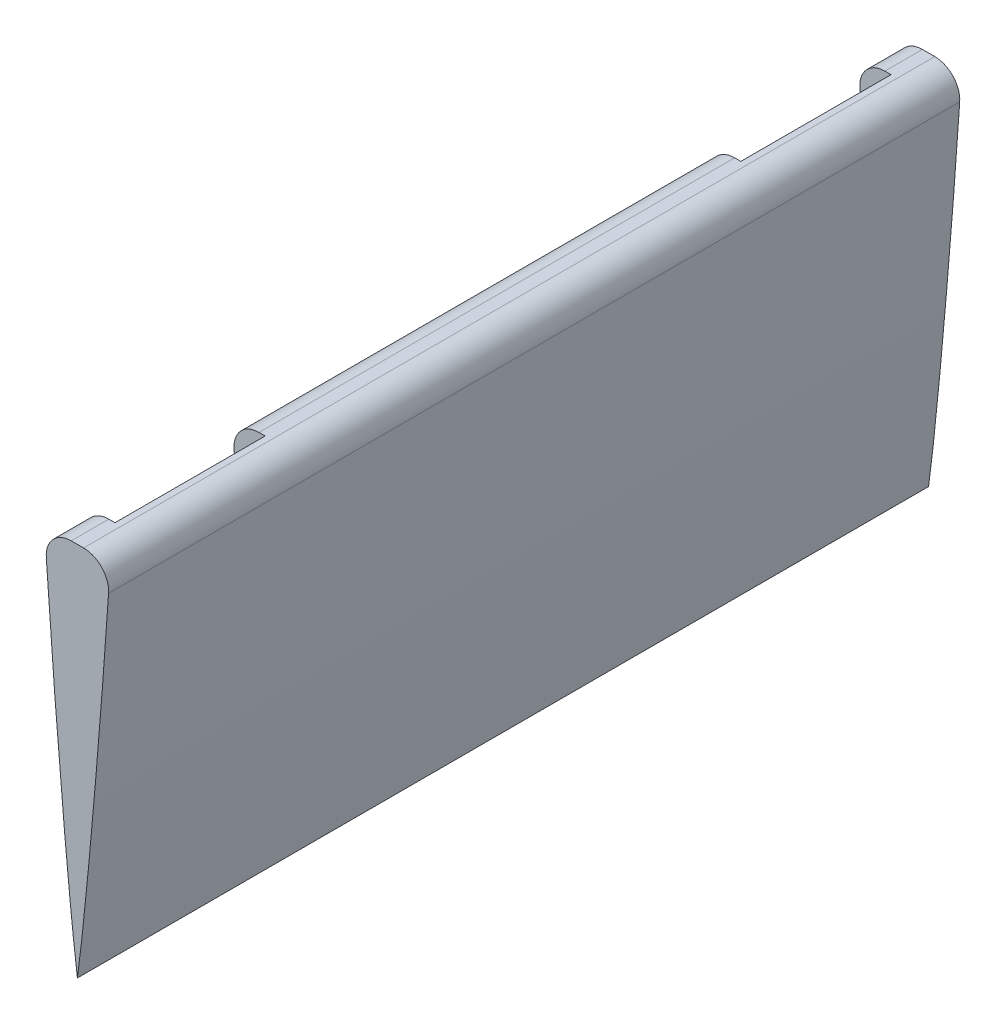
from build123d import *

# Parameters (mm, degrees)
BOSS_EXTRUDE1_DEPTH = 34
SKETCH4_W           = 12
SKETCH4_H           = 12
CUT_EXTRUDE1_DEPTH  = 3.493295554


with BuildPart() as part:
    # Sketch2 → Boss-Extrude1 (new body, symmetric)
    with BuildSketch(Plane.XY.offset(35)):
        with BuildLine():
            Line((-0.493295454, -665), (0.493295611, -665))
            ThreePointArc((0.493295611, -665), (1.954790004, -665.634703644), (2.488668579, -667.135965861))
            add(Edge.make_bspline(
                [(0, -695), (0.015522073, -694.884094445), (0.077278927, -694.422947112), (0.206148599, -693.392547034), (0.403716276, -691.694585868), (0.648953841, -689.357636132), (0.936738043, -686.422103162), (1.254326755, -682.93824868), (1.595587122, -678.965683583), (1.950533146, -674.572635912), (2.249009374, -670.582285025), (2.425394007, -668.064554633), (2.488668579, -667.135965861)],
                knots=[0.816447502, 0.816447502, 0.816447502, 0.816447502, 0.818585491, 0.824953805, 0.835432492, 0.849837851, 0.867913595, 0.889359146, 0.913796005, 0.94081031, 0.969937518, 0.986954026, 0.986954026, 0.986954026, 0.986954026], degree=3))
            Line((0, -695), (-0.0463125, -694.65225))
            add(Edge.make_bspline(
                [(-2.488668416, -667.135965964), (-2.425393799, -668.064554688), (-2.249009192, -670.582285042), (-1.950535166, -674.572636178), (-1.595580455, -678.965682707), (-1.254347923, -682.938251461), (-0.936673997, -686.422094747), (-0.649135543, -689.357660004), (-0.403246318, -691.694524123), (-0.207189019, -693.39268373), (-0.090443378, -694.3067318), (-0.0463125, -694.65225)],
                knots=[0.013045974, 0.013045974, 0.013045974, 0.013045974, 0.030062482, 0.05918969, 0.086203995, 0.110640854, 0.132086405, 0.150162149, 0.164567508, 0.175046195, 0.181414509, 0.181414509, 0.181414509, 0.181414509], degree=3))
            ThreePointArc((-2.488668416, -667.135965964), (-1.954789882, -665.634703682), (-0.493295454, -665))
        make_face()
    extrude(amount=BOSS_EXTRUDE1_DEPTH, both=True)

    # Sketch4 → Cut-Extrude1 (cut, through all)
    with BuildSketch(Plane.ZY):
        with Locations((60, -671)):
            Rectangle(SKETCH4_W, SKETCH4_H)
        with Locations((10, -671)):
            Rectangle(SKETCH4_W, SKETCH4_H)
    extrude(amount=CUT_EXTRUDE1_DEPTH, mode=Mode.SUBTRACT)


solid = part.part
